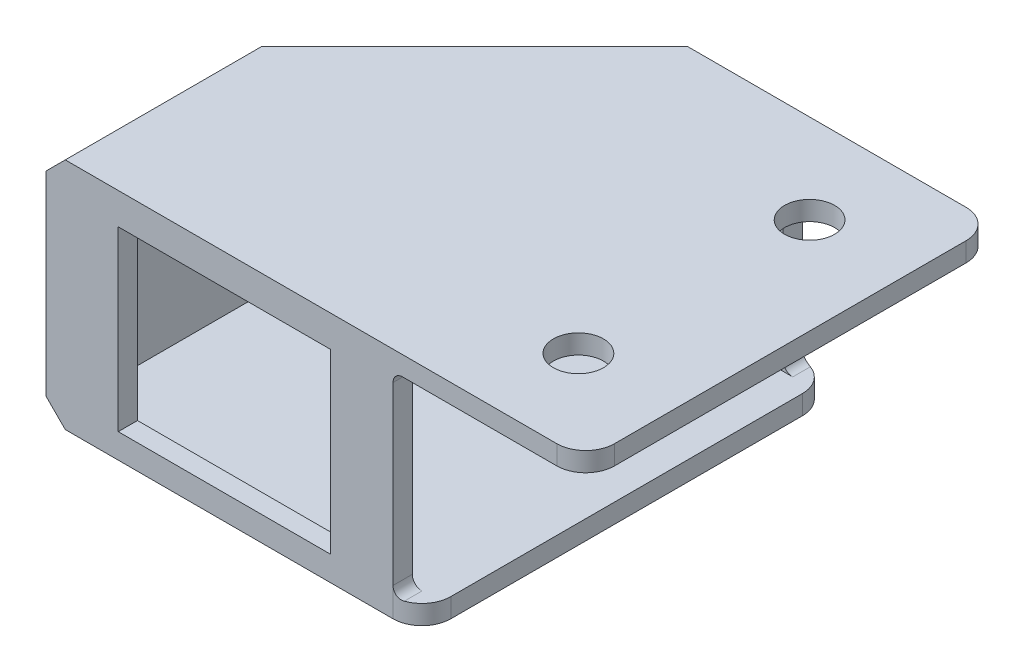
from build123d import *

# Parameters (mm, degrees)
SKETCH1_W           = 32.03
SKETCH1_H           = 20.25
BOSS_EXTRUDE1_DEPTH = 42.5
SKETCH2_W           = 32.03
SKETCH2_H           = 20.25
SKETCH2_W_2         = 22.03
SKETCH2_H_2         = 18.42
BOSS_EXTRUDE2_DEPTH = 2
CUT_EXTRUDE1_DEPTH  = 25.25
FILLET1_R           = 3
SKETCH6_R           = 2.6
CUT_EXTRUDE3_DEPTH  = 25.25
CHAMFER2_SIZE       = 2
BOSS_EXTRUDE3_REACH = 24.25
CUT_EXTRUDE4_REACH  = 38.03
SKETCH8_W           = 38.5
SKETCH8_H           = 20.25
FILLET2_R           = 1


with BuildPart() as part:
    # Sketch1 → Boss-Extrude1 (new body)
    with BuildSketch(Plane.XY):
        Polygon((26.409748294, 13.899702025), (26.409748294, -6.350297975), (29.409748294, -6.350297975), (29.409748294, -8.350297975), (-9.620251706, -8.350297975), (-9.620251706, 15.899702025), (46.409748294, 15.899702025), (46.409748294, 13.899702025), align=None)
        with Locations((8.394748294, 3.774702025)):
            Rectangle(SKETCH1_W, SKETCH1_H, mode=Mode.SUBTRACT)
    extrude(amount=BOSS_EXTRUDE1_DEPTH)

    # Sketch2 → Boss-Extrude2 (add)
    with BuildSketch(Plane.XY.offset(42.5)):
        with Locations((8.394748294, 3.774702025)):
            Rectangle(SKETCH2_W, SKETCH2_H)
        with Locations((8.894748294, 3.422592454)):
            Rectangle(SKETCH2_W_2, SKETCH2_H_2, mode=Mode.SUBTRACT)
    extrude(amount=-BOSS_EXTRUDE2_DEPTH)

    # Sketch3 → Cut-Extrude1 (cut, through all)
    with BuildSketch(Plane.XZ.offset(8.350297975)):
        Polygon((-9.620251706, 0), (-9.620251706, 21.25), (11.629748294, 0), align=None)
    extrude(amount=-CUT_EXTRUDE1_DEPTH, mode=Mode.SUBTRACT)

    # Fillet1
    fillet1_edges = [part.edges().sort_by_distance(p)[0] for p in [
        (46.409748294, 14.899702025, 0),
        (29.409748294, -7.350297975, 0),
        (46.409748294, 14.899702025, 42.5),
        (29.409748294, -7.350297975, 42.5),
    ]]
    fillet(fillet1_edges, radius=FILLET1_R)

    # Sketch6 → Cut-Extrude3 (cut, through all)
    with BuildSketch(Plane(origin=(0, 15.899702025, 0), x_dir=(1, 0, 0), z_dir=(0, 1, 0))):
        with Locations((36.409748294, -33.25)):
            Circle(SKETCH6_R)
        with Locations((36.409748294, -9.25)):
            Circle(SKETCH6_R)
    extrude(amount=-CUT_EXTRUDE3_DEPTH, mode=Mode.SUBTRACT)

    # Chamfer2
    chamfer2_edges = [part.edges().sort_by_distance(p)[0] for p in [
        (1.004748294, 15.899702025, 10.625),
        (-9.620251706, 15.899702025, 31.875),
        (1.004748294, -8.350297975, 10.625),
        (-9.620251706, -8.350297975, 31.875),
    ]]
    chamfer(chamfer2_edges, length=CHAMFER2_SIZE)

    # Sketch7 → Boss-Extrude3 (add, up to next)
    with BuildSketch(Plane(origin=(0, -6.350297975, 0), x_dir=(1, 0, 0), z_dir=(0, 1, 0)), mode=Mode.PRIVATE) as boss_extrude3_sk1:
        Polygon((24.409748294, 0), (11.629748294, 0), (-7.620251706, -19.25), (-7.620251706, -22.078427125), (12.458175419, -2), (24.409748294, -2), align=None)
    boss_extrude3_tool1 = extrude(boss_extrude3_sk1.sketch, amount=BOSS_EXTRUDE3_REACH, mode=Mode.PRIVATE) - part.part
    add(boss_extrude3_tool1.solids().sort_by_distance((18.019748, -6.350298, 0.389022))[0])

    # Sketch8 → Cut-Extrude4 (cut, up to next)
    with BuildSketch(Plane(origin=(26.409748294, 0, 0), x_dir=(0, 0, -1), z_dir=(1, 0, 0)), mode=Mode.PRIVATE) as cut_extrude4_sk1:
        with Locations((-21.25, 3.774702025)):
            Rectangle(SKETCH8_W, SKETCH8_H)
    cut_extrude4_tool1 = extrude(cut_extrude4_sk1.sketch, amount=-CUT_EXTRUDE4_REACH, mode=Mode.PRIVATE) & part.part
    add(cut_extrude4_tool1.solids().sort_by_distance((26.409748, 3.774702, 21.25))[0], mode=Mode.SUBTRACT)

    # Fillet2
    fillet2_edges = [part.edges().sort_by_distance(p)[0] for p in [
        (26.409748294, 13.899702025, 1),
        (26.409748294, -6.350297975, 1),
        (26.409748294, 13.899702025, 41.5),
        (26.409748294, -6.350297975, 41.5),
    ]]
    fillet(fillet2_edges, radius=FILLET2_R)


solid = part.part
